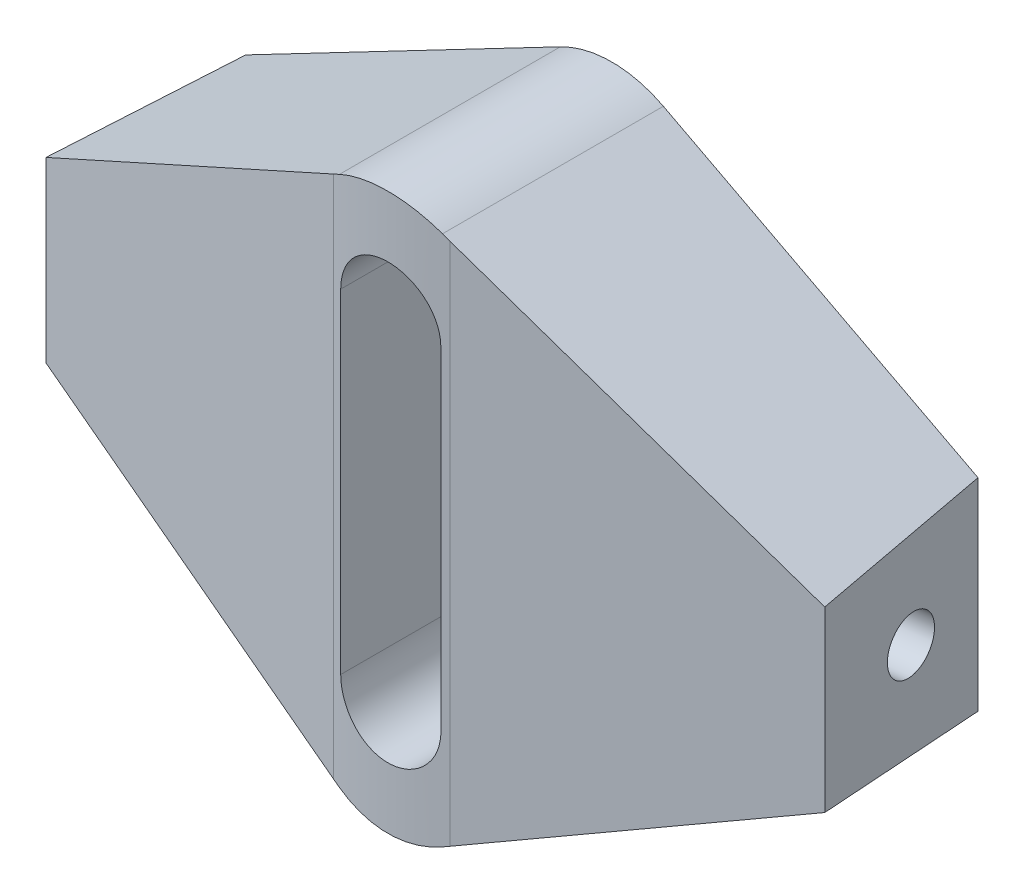
from build123d import *

# Parameters (mm, degrees)
AUFSATZ_LINEAR_AUSTRAGEN3_DEPTH      = 20
SCHNITT_LINEAR_AUSTRAGEN9_DEPTH      = 30.368350311
SCHNITT_LINEAR_AUSTRAGEN9_DEPTH_BACK = 30.368350311
SKIZZE10_OUTSIDE_W                   = 46.486
SKIZZE10_OUTSIDE_H                   = 31.486
SKIZZE7_R                            = 1.23
SCHNITT_LINEAR_AUSTRAGEN8_DEPTH      = 12


with BuildPart() as part:
    # Skizze3 → Aufsatz-Linear austragen3 (new body)
    with BuildSketch(Plane.XY):
        with BuildLine():
            Line((-2.314936357, 11.931824643), (-17.5, 4))
            Line((-17.5, 4), (-17.5, -4))
            Line((-17.5, -4), (-2.314936357, -11.931824643))
            ThreePointArc((-2.314936357, -11.931824643), (0, -12.5), (2.314936357, -11.931824643))
            Line((2.314936357, -11.931824643), (17.5, -4))
            Line((17.5, -4), (17.5, 4))
            Line((17.5, 4), (2.314936357, 11.931824643))
            ThreePointArc((2.314936357, 11.931824643), (0, 12.5), (-2.314936357, 11.931824643))
        make_face()
        with BuildLine():
            ThreePointArc((2.25, -7.5), (0, -9.75), (-2.25, -7.5))
            Line((-2.25, -7.5), (-2.25, 7.5))
            ThreePointArc((-2.25, 7.5), (0, 9.75), (2.25, 7.5))
            Line((2.25, 7.5), (2.25, -7.5))
        make_face(mode=Mode.SUBTRACT)
    extrude(amount=AUFSATZ_LINEAR_AUSTRAGEN3_DEPTH)

    # Skizze10 outside → Schnitt-Linear austragen9 (cut, two sides: drawn at the far end of the back side and taken through both)
    with BuildSketch(Plane(origin=(0, 0, 0), x_dir=(1, 0, 0), z_dir=(0, 1, 0)).offset(-SCHNITT_LINEAR_AUSTRAGEN9_DEPTH_BACK)):
        with Locations((0, -10)):
            Rectangle(SKIZZE10_OUTSIDE_W, SKIZZE10_OUTSIDE_H)
        with BuildLine():
            Line((-16.455790462, 0), (-17.5, -7.931558891))
            Line((-17.5, -7.931558891), (-2.610523844, -9.891795615))
            ThreePointArc((-2.610523844, -9.891795615), (0, -10.062898387), (2.610523844, -9.891795615))
            Line((2.610523844, -9.891795615), (17.5, -7.931558891))
            Line((17.5, -7.931558891), (16.455790462, 0))
            Line((16.455790462, 0), (-16.455790462, 0))
        make_face(mode=Mode.SUBTRACT)
    extrude(amount=SCHNITT_LINEAR_AUSTRAGEN9_DEPTH + SCHNITT_LINEAR_AUSTRAGEN9_DEPTH_BACK, mode=Mode.SUBTRACT)

    # Skizze7 → Schnitt-Linear austragen8 (cut)
    with BuildSketch(Plane(origin=(-17.19638108, 0, 5.625344227), x_dir=(-0.1305261922200491, 0, 0.9914448613738107), z_dir=(-0.9914448613738107, 0, -0.1305261922200491))):
        with Locations((-2.173885101, 0)):
            Circle(SKIZZE7_R)
    schnitt_linear_austragen8 = extrude(amount=-SCHNITT_LINEAR_AUSTRAGEN8_DEPTH, mode=Mode.SUBTRACT)

    # Spiegeln4: Schnitt-Linear austragen8 across plane
    add(schnitt_linear_austragen8.mirror(Plane(origin=(0, 0, 0), x_dir=(0, 0, 1), z_dir=(1, 0, 0))), mode=Mode.SUBTRACT)


solid = part.part
